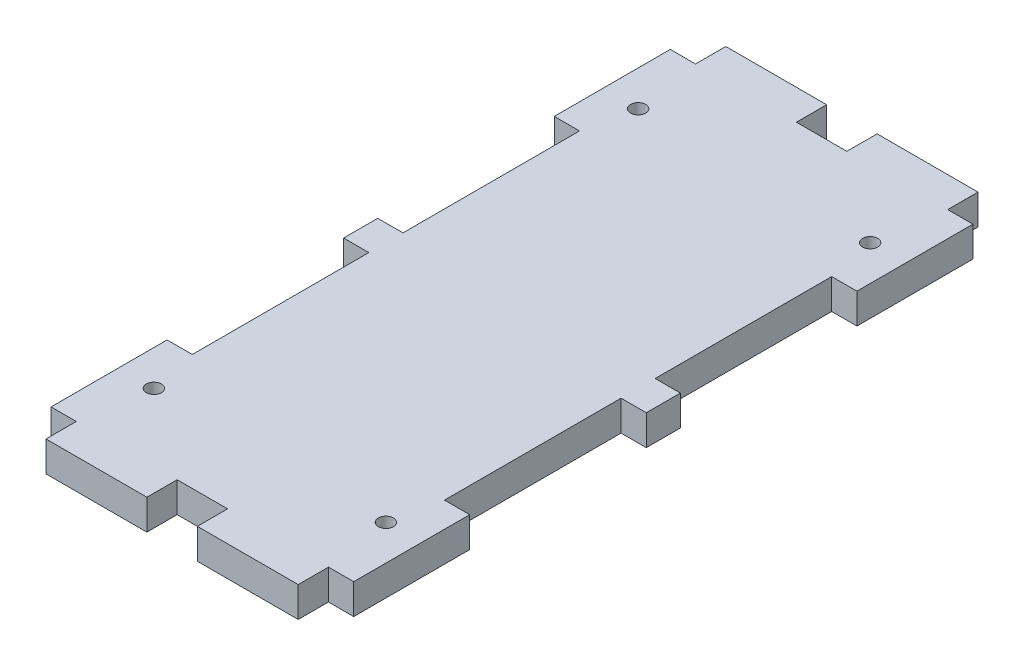
from build123d import *

# Parameters (mm, degrees)
ESQUISSE1_W             = 60
ESQUISSE1_H             = 122.76
BOSS_EXTRU_1_DEPTH      = 6
ESQUISSE2_W             = 20
ESQUISSE2_H             = 6
BOSS_EXTRU_2_DEPTH      = 6
ESQUISSE3_R             = 1.5
ENL_V_MAT_EXTRU_1_DEPTH = 6
ESQUISSE4_W             = 5
ESQUISSE4_H             = 35
ENL_V_MAT_EXTRU_2_DEPTH = 6


with BuildPart() as part:
    # Esquisse1 → Boss.-Extru.1 (new body)
    with BuildSketch(Plane(origin=(0, 0, 0), x_dir=(1, 0, 0), z_dir=(0, 1, 0))):
        Rectangle(ESQUISSE1_W, ESQUISSE1_H)
    extrude(amount=BOSS_EXTRU_1_DEPTH)

    # Esquisse2 → Boss.-Extru.2 (add)
    with BuildSketch(Plane(origin=(0, 6, 0), x_dir=(1, 0, 0), z_dir=(0, 1, 0))):
        with Locations((-15, 64.38)):
            Rectangle(ESQUISSE2_W, ESQUISSE2_H)
        with Locations((15, 64.38)):
            Rectangle(ESQUISSE2_W, ESQUISSE2_H)
        with Locations((15, -64.38)):
            Rectangle(ESQUISSE2_W, ESQUISSE2_H)
        with Locations((-15, -64.38)):
            Rectangle(ESQUISSE2_W, ESQUISSE2_H)
    extrude(amount=-BOSS_EXTRU_2_DEPTH)

    # Esquisse3 → Enlèv. mat.-Extru.1 (cut)
    with BuildSketch(Plane(origin=(0, 6, 0), x_dir=(1, 0, 0), z_dir=(0, 1, 0))):
        with Locations((23, 48)):
            Circle(ESQUISSE3_R)
        with Locations((-23, 48)):
            Circle(ESQUISSE3_R)
        with Locations((-23, -48)):
            Circle(ESQUISSE3_R)
        with Locations((23, -48)):
            Circle(ESQUISSE3_R)
    extrude(amount=-ENL_V_MAT_EXTRU_1_DEPTH, mode=Mode.SUBTRACT)

    # Esquisse4 → Enlèv. mat.-Extru.2 (cut)
    with BuildSketch(Plane(origin=(0, 6, 0), x_dir=(1, 0, 0), z_dir=(0, 1, 0))):
        with Locations((-27.5, -20.88)):
            Rectangle(ESQUISSE4_W, ESQUISSE4_H)
        with Locations((27.5, -20.88)):
            Rectangle(ESQUISSE4_W, ESQUISSE4_H)
        with Locations((-27.5, 20.88)):
            Rectangle(ESQUISSE4_W, ESQUISSE4_H)
        with Locations((27.5, 20.88)):
            Rectangle(ESQUISSE4_W, ESQUISSE4_H)
    extrude(amount=-ENL_V_MAT_EXTRU_2_DEPTH, mode=Mode.SUBTRACT)


solid = part.part
